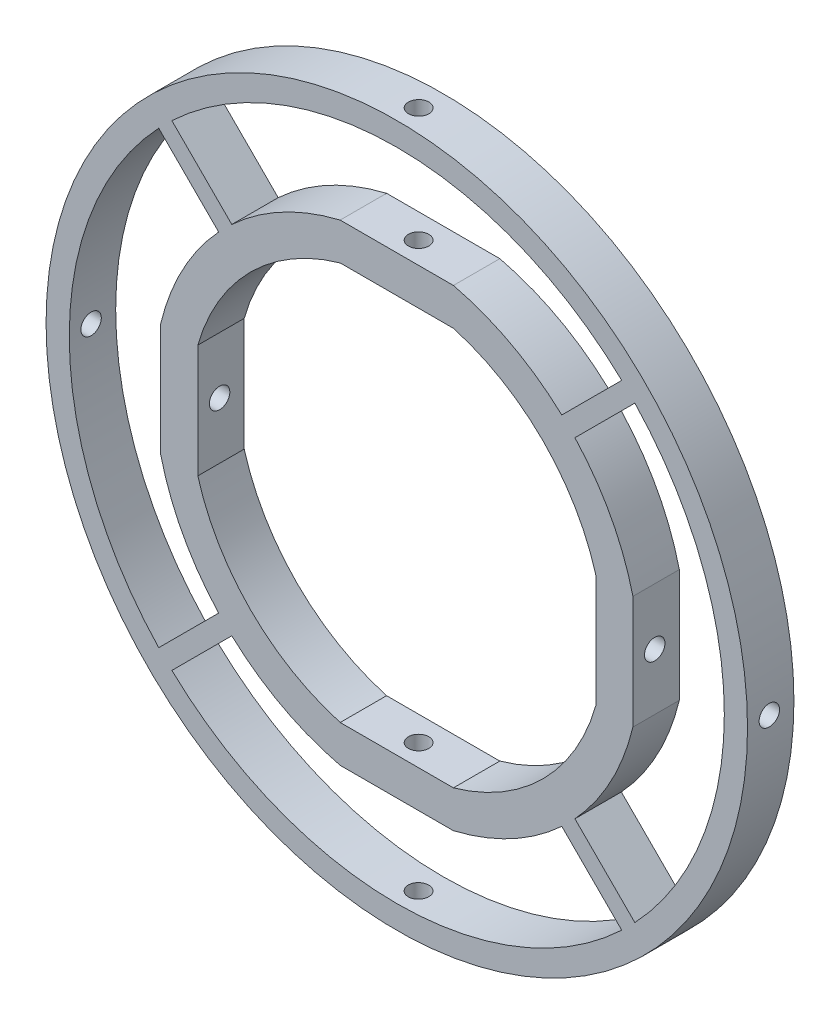
from build123d import *

# Parameters (mm, degrees)
BOSS_EXTRUDE1_DEPTH = 5
CUT_EXTRUDE2_START  = -4
SKETCH3_R           = 1.1
CUT_EXTRUDE2_DEPTH  = 5
CIRPATTERN7_COUNT   = 4
SKETCH4_R           = 37.79
BOSS_EXTRUDE2_DEPTH = 5
SKETCH5_R           = 1.1
CUT_EXTRUDE3_DEPTH  = 13.35
CIRPATTERN8_COUNT   = 4


with BuildPart() as part:
    # Sketch1 → Boss-Extrude1 (new body)
    with BuildSketch(Plane.XY):
        with BuildLine():
            Line((-6.1, 25.44), (6.1, 25.44))
            ThreePointArc((6.1, 25.44), (18.498697251, 18.498697251), (25.44, 6.1))
            Line((25.44, 6.1), (25.44, -6.1))
            ThreePointArc((25.44, -6.1), (18.498697251, -18.498697251), (6.1, -25.44))
            Line((6.1, -25.44), (-6.1, -25.44))
            ThreePointArc((-6.1, -25.44), (-18.498697251, -18.498697251), (-25.44, -6.1))
            Line((-25.44, -6.1), (-25.44, 6.1))
            ThreePointArc((-25.44, 6.1), (-18.498697251, 18.498697251), (-6.1, 25.44))
        make_face()
        with BuildLine():
            Line((-6.1, 21.44), (6.1, 21.44))
            ThreePointArc((6.1, 21.44), (15.76203667, 15.76203667), (21.44, 6.1))
            Line((21.44, 6.1), (21.44, -6.1))
            ThreePointArc((21.44, -6.1), (15.76203667, -15.76203667), (6.1, -21.44))
            Line((6.1, -21.44), (-6.1, -21.44))
            ThreePointArc((-6.1, -21.44), (-15.76203667, -15.76203667), (-21.44, -6.1))
            Line((-21.44, -6.1), (-21.44, 6.1))
            ThreePointArc((-21.44, 6.1), (-15.76203667, 15.76203667), (-6.1, 21.44))
        make_face(mode=Mode.SUBTRACT)
    extrude(amount=BOSS_EXTRUDE1_DEPTH)

    # Sketch3 → Cut-Extrude2 (cut)
    with BuildSketch(Plane(origin=(0, 25.44, 0), x_dir=(1, 0, 0), z_dir=(0, 1, 0)).offset(CUT_EXTRUDE2_START)):
        with Locations((0, -2.65)):
            Circle(SKETCH3_R)
    cut_extrude2 = extrude(amount=CUT_EXTRUDE2_DEPTH, mode=Mode.SUBTRACT)

    # CirPattern7: Cut-Extrude2 ×4 about axis
    cirpattern7_axis = Axis((0, 0, 5), (0, 0, -1))
    for i in range(1, CIRPATTERN7_COUNT):
        add(cut_extrude2.rotate(cirpattern7_axis, i * 360 / CIRPATTERN7_COUNT), mode=Mode.SUBTRACT)

    # Sketch4 → Boss-Extrude2 (add)
    with BuildSketch(Plane.XY.offset(5)):
        Circle(SKETCH4_R)
        with BuildLine():
            Line((-25.650884562, 24.236671), (-19.192284627, 17.778071065))
            ThreePointArc((-19.192284627, 17.778071065), (-18.498697251, 18.498697251), (-17.778071065, 19.192284627))
            Line((-17.778071065, 19.192284627), (-24.236671, 25.650884562))
            ThreePointArc((-24.236671, 25.650884562), (0, 35.29), (24.236671, 25.650884562))
            Line((24.236671, 25.650884562), (17.778071065, 19.192284627))
            ThreePointArc((17.778071065, 19.192284627), (18.498697251, 18.498697251), (19.192284627, 17.778071065))
            Line((19.192284627, 17.778071065), (25.650884562, 24.236671))
            ThreePointArc((25.650884562, 24.236671), (35.29, 0), (25.650884562, -24.236671))
            Line((25.650884562, -24.236671), (19.192284627, -17.778071065))
            ThreePointArc((19.192284627, -17.778071065), (18.498697251, -18.498697251), (17.778071065, -19.192284627))
            Line((17.778071065, -19.192284627), (24.236671, -25.650884562))
            ThreePointArc((24.236671, -25.650884562), (0, -35.29), (-24.236671, -25.650884562))
            Line((-24.236671, -25.650884562), (-17.778071065, -19.192284627))
            ThreePointArc((-17.778071065, -19.192284627), (-18.498697251, -18.498697251), (-19.192284627, -17.778071065))
            Line((-19.192284627, -17.778071065), (-25.650884562, -24.236671))
            ThreePointArc((-25.650884562, -24.236671), (-35.29, 0), (-25.650884562, 24.236671))
        make_face(mode=Mode.SUBTRACT)
    extrude(amount=-BOSS_EXTRUDE2_DEPTH)

    # Sketch5 → Cut-Extrude3 (cut, through all)
    with BuildSketch(Plane.ZY.offset(25.44)):
        with Locations((2.65, 0)):
            Circle(SKETCH5_R)
    cut_extrude3 = extrude(amount=CUT_EXTRUDE3_DEPTH, mode=Mode.SUBTRACT)

    # CirPattern8: Cut-Extrude3 ×4 about axis
    cirpattern8_axis = Axis((0, 0, -106.886261044), (0, 0, 1))
    for i in range(1, CIRPATTERN8_COUNT):
        add(cut_extrude3.rotate(cirpattern8_axis, i * 360 / CIRPATTERN8_COUNT), mode=Mode.SUBTRACT)


solid = part.part
